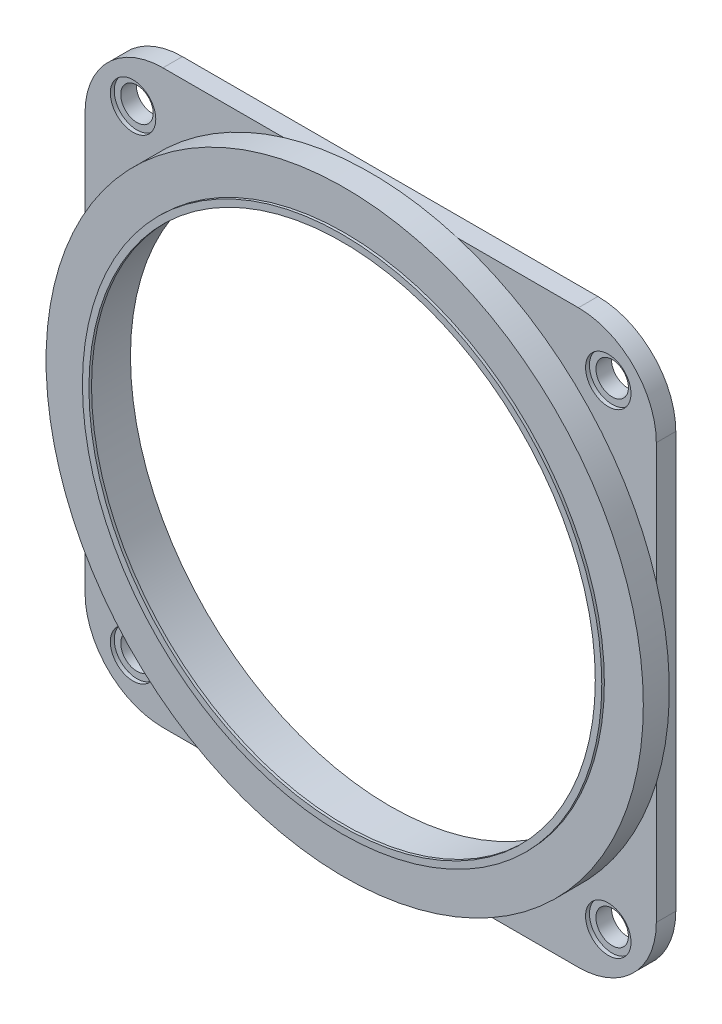
from build123d import *

# Parameters (mm, degrees)
SALIENTE_EXTRUIR1_DEPTH = 1.5
CROQUIS2_R              = 20
CORTAR_EXTRUIR1_DEPTH   = 2.5
CROQUIS3_R              = 23
CROQUIS3_R_2            = 20
SALIENTE_EXTRUIR2_DEPTH = 2
CROQUIS4_R              = 1.25
CORTAR_EXTRUIR2_DEPTH   = 2
CROQUIS6_R              = 1.75
CORTAR_EXTRUIR3_DEPTH   = 0.3
CROQUIS7_R              = 20
CROQUIS7_R_2            = 19.5
SALIENTE_EXTRUIR3_DEPTH = 0.2


with BuildPart() as part:
    # Croquis1 → Saliente-Extruir1 (new body)
    with BuildSketch(Plane.XY):
        with BuildLine():
            Line((-16, 22), (16, 22))
            ThreePointArc((16, 22), (20.242640687, 20.242640687), (22, 16))
            Line((22, 16), (22, -16))
            ThreePointArc((22, -16), (20.242640687, -20.242640687), (16, -22))
            Line((16, -22), (-16, -22))
            ThreePointArc((-16, -22), (-20.242640687, -20.242640687), (-22, -16))
            Line((-22, -16), (-22, 16))
            ThreePointArc((-22, 16), (-20.242640687, 20.242640687), (-16, 22))
        make_face()
    extrude(amount=SALIENTE_EXTRUIR1_DEPTH)

    # Croquis2 → Cortar-Extruir1 (cut, through all)
    with BuildSketch(Plane.XY.offset(1.5)):
        Circle(CROQUIS2_R)
    extrude(amount=-CORTAR_EXTRUIR1_DEPTH, mode=Mode.SUBTRACT)

    # Croquis3 → Saliente-Extruir2 (add)
    with BuildSketch(Plane.XY.offset(1.5)):
        Circle(CROQUIS3_R)
        Circle(CROQUIS3_R_2, mode=Mode.SUBTRACT)
    extrude(amount=SALIENTE_EXTRUIR2_DEPTH)

    # Croquis4 → Cortar-Extruir2 (cut)
    with BuildSketch(Plane.XY.offset(1.5)):
        with Locations((18.3, 18.3)):
            Circle(CROQUIS4_R)
        with Locations((-18.3, 18.3)):
            Circle(CROQUIS4_R)
        with Locations((18.3, -18.3)):
            Circle(CROQUIS4_R)
        with Locations((-18.3, -18.3)):
            Circle(CROQUIS4_R)
    extrude(amount=-CORTAR_EXTRUIR2_DEPTH, mode=Mode.SUBTRACT)

    # Croquis6 → Cortar-Extruir3 (cut)
    with BuildSketch(Plane.XY.offset(1.5)):
        with Locations((18.3, 18.3)):
            Circle(CROQUIS6_R)
        with Locations((-18.3, 18.3)):
            Circle(CROQUIS6_R)
        with Locations((-18.3, -18.3)):
            Circle(CROQUIS6_R)
        with Locations((18.3, -18.3)):
            Circle(CROQUIS6_R)
    extrude(amount=-CORTAR_EXTRUIR3_DEPTH, mode=Mode.SUBTRACT)


with BuildPart() as body_2:
    # Croquis7 → Saliente-Extruir3 (new body)
    with BuildSketch(Plane.XY.offset(3.5)):
        Circle(CROQUIS7_R)
        Circle(CROQUIS7_R_2, mode=Mode.SUBTRACT)
    extrude(amount=SALIENTE_EXTRUIR3_DEPTH)


solid = Compound([part.part, body_2.part])
